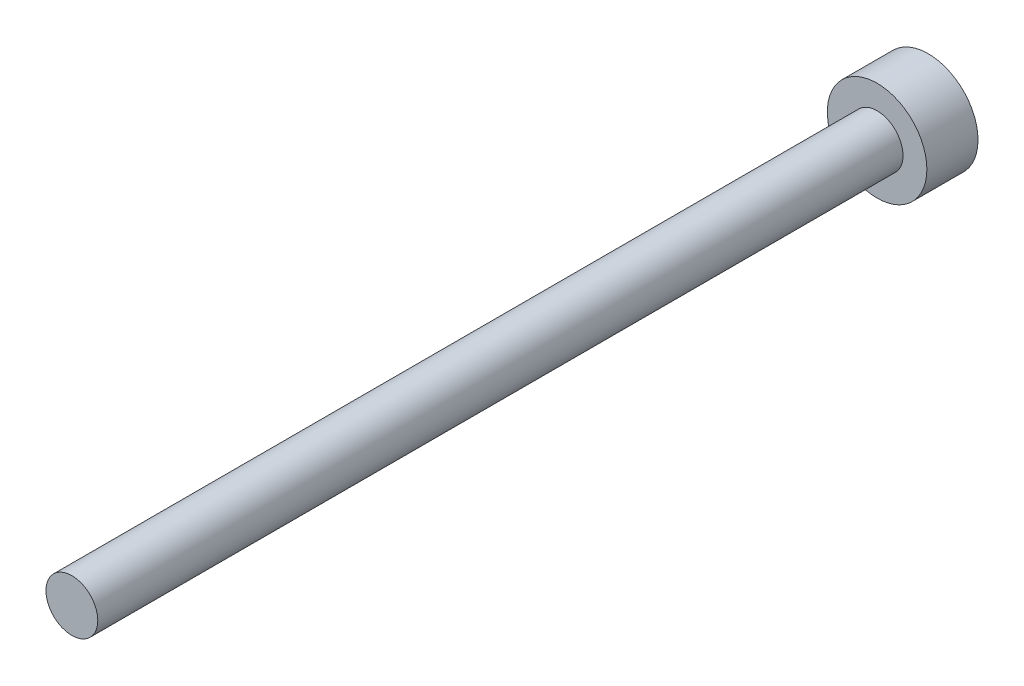
from build123d import *

# Parameters (mm, degrees)
SKETCH1_R           = 0.9652
BOSS_EXTRUDE1_DEPTH = 30
SKETCH2_R           = 1.8542
BOSS_EXTRUDE2_DEPTH = 1.905
CUT_EXTRUDE1_DEPTH  = 1.524


with BuildPart() as part:
    # Sketch1 → Boss-Extrude1 (new body)
    with BuildSketch(Plane.XY):
        Circle(SKETCH1_R)
    extrude(amount=BOSS_EXTRUDE1_DEPTH)

    # Sketch2 → Boss-Extrude2 (add)
    with BuildSketch(Plane.XY):
        Circle(SKETCH2_R)
    extrude(amount=-BOSS_EXTRUDE2_DEPTH)

    # Sketch3 → Cut-Extrude1 (cut)
    with BuildSketch(Plane(origin=(0, 0, -1.905), x_dir=(-1, 0, 0), z_dir=(0, 0, -1))):
        Polygon((0.850552417, 0), (0.425276208, 0.7366), (-0.425276208, 0.7366), (-0.850552417, 0), (-0.425276208, -0.7366), (0.425276208, -0.7366), align=None)
    extrude(amount=-CUT_EXTRUDE1_DEPTH, mode=Mode.SUBTRACT)


solid = part.part
